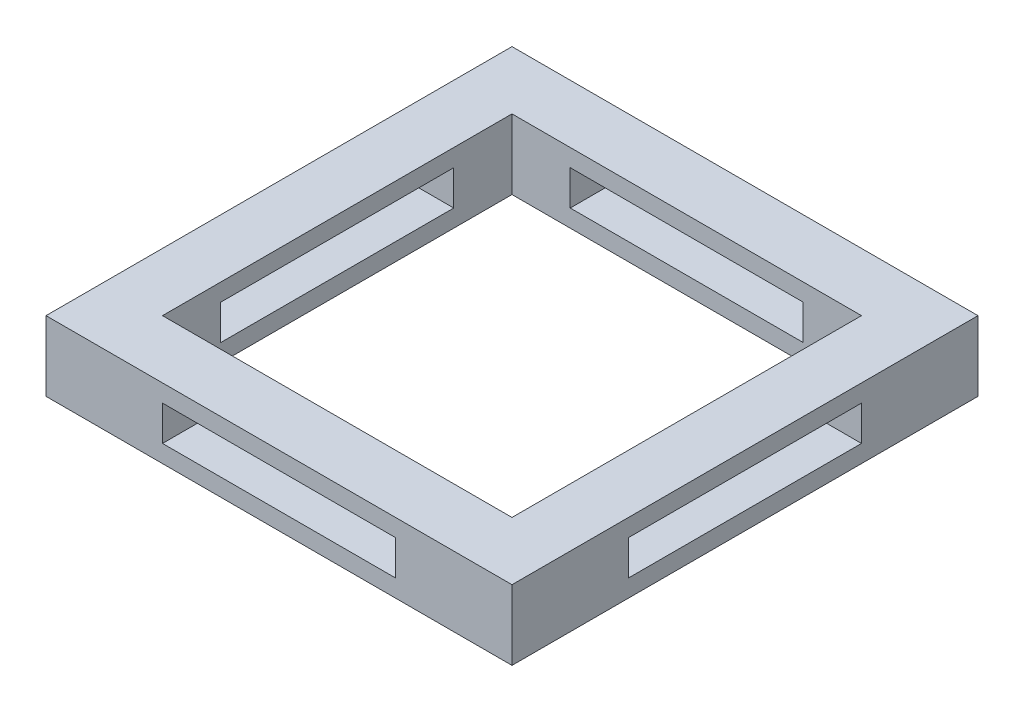
from build123d import *

# Parameters (mm, degrees)
SKETCH1_W           = 20
SKETCH1_H           = 20
SKETCH1_W_2         = 15
SKETCH1_H_2         = 15
BOSS_EXTRUDE1_DEPTH = 3
SKETCH2_W           = 10
SKETCH2_H           = 1.5
CUT_EXTRUDE1_DEPTH  = 21
SKETCH3_W           = 10
SKETCH3_H           = 1.5
CUT_EXTRUDE2_DEPTH  = 21


with BuildPart() as part:
    # Sketch1 → Boss-Extrude1 (new body)
    with BuildSketch(Plane(origin=(0, 0, 0), x_dir=(1, 0, 0), z_dir=(0, 1, 0))):
        Rectangle(SKETCH1_W, SKETCH1_H)
        Rectangle(SKETCH1_W_2, SKETCH1_H_2, mode=Mode.SUBTRACT)
    extrude(amount=BOSS_EXTRUDE1_DEPTH)

    # Sketch2 → Cut-Extrude1 (cut, through all)
    with BuildSketch(Plane.XY.offset(10)):
        with Locations((0, 1.5)):
            Rectangle(SKETCH2_W, SKETCH2_H)
    extrude(amount=-CUT_EXTRUDE1_DEPTH, mode=Mode.SUBTRACT)

    # Sketch3 → Cut-Extrude2 (cut, through all)
    with BuildSketch(Plane.ZY.offset(10)):
        with Locations((0, 1.5)):
            Rectangle(SKETCH3_W, SKETCH3_H)
    extrude(amount=-CUT_EXTRUDE2_DEPTH, mode=Mode.SUBTRACT)


solid = part.part
